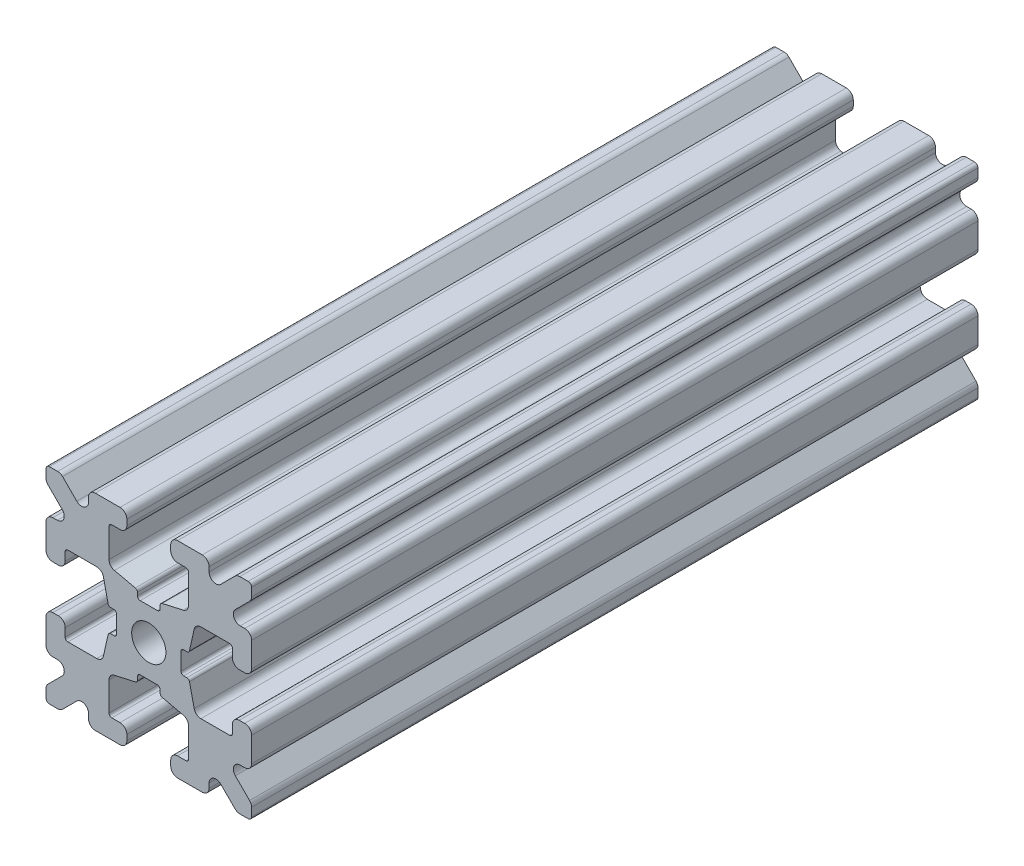
from build123d import *

# Parameters (mm, degrees)
SKETCH1_W           = 15
SKETCH1_H           = 15
SKETCH1_R           = 1.25
BOSS_EXTRUDE1_DEPTH = 26.5
FILLET1_R           = 0.25
CUT_EXTRUDE1_DEPTH  = 54
CUT_EXTRUDE3_DEPTH  = 54
FILLET3_R           = 0.5
FILLET4_R           = 0.5
FILLET5_R           = 3
FILLET6_R           = 0.2
CUT_EXTRUDE4_DEPTH  = 54
FILLET8_R           = 0.5
SKETCH6_W           = 5.1529354
SKETCH6_H           = 1.651
SKETCH6_W_2         = 1.651
SKETCH6_H_2         = 5.1529354
CUT_EXTRUDE5_DEPTH  = 54
FILLET10_R          = 0.2


with BuildPart() as part:
    # Sketch1 → Boss-Extrude1 (new body, symmetric)
    with BuildSketch(Plane.XY):
        Rectangle(SKETCH1_W, SKETCH1_H)
        Circle(SKETCH1_R, mode=Mode.SUBTRACT)
    extrude(amount=BOSS_EXTRUDE1_DEPTH, both=True)

    # Fillet1
    fillet1_edges = [part.edges().sort_by_distance(p)[0] for p in [
        (7.5, -7.5, 0),
        (-7.5, -7.5, 0),
        (-7.5, 7.5, 0),
        (7.5, 7.5, 0),
    ]]
    fillet(fillet1_edges, radius=FILLET1_R)

    # Sketch2 → Cut-Extrude1 (cut, through all)
    with BuildSketch(Plane.XY.offset(26.5)):
        Polygon((-7.5, 1.6), (-6.1, 1.6), (-6.1, 2.9), (-3.4, 2.9), (-3.4, -2.9), (-6.1, -2.9), (-6.1, -1.6), (-7.5, -1.6), align=None)
        Polygon((2.9, 6.1), (1.6, 6.1), (1.6, 7.5), (-1.6, 7.5), (-1.6, 6.1), (-2.9, 6.1), (-2.9, 3.4), (2.9, 3.4), align=None)
        Polygon((-1.6, -7.5), (-1.6, -6.1), (-2.9, -6.1), (-2.9, -3.4), (2.9, -3.4), (2.9, -6.1), (1.6, -6.1), (1.6, -7.5), align=None)
        Polygon((6.1, -2.9), (6.1, -1.6), (7.5, -1.6), (7.5, 1.6), (6.1, 1.6), (6.1, 2.9), (3.4, 2.9), (3.4, -2.9), align=None)
    extrude(amount=-CUT_EXTRUDE1_DEPTH, mode=Mode.SUBTRACT)

    # Sketch4 → Cut-Extrude3 (cut, through all)
    with BuildSketch(Plane.XY.offset(26.5)):
        Polygon((-3.4, 2.9), (-2.75, 0), (-3.4, -2.9), align=None)
        Polygon((-2.9, 3.4), (0, 2.75), (2.9, 3.4), align=None)
        Polygon((3.4, 2.9), (2.75, 0), (3.4, -2.9), align=None)
        Polygon((-2.9, -3.4), (0, -2.75), (2.9, -3.4), align=None)
    extrude(amount=-CUT_EXTRUDE3_DEPTH, mode=Mode.SUBTRACT)

    # Fillet3
    fillet3_edges = [part.edges().sort_by_distance(p)[0] for p in [
        (1.6, -7.5, 0),
        (-1.6, -7.5, 0),
        (-1.6, -6.1, 0),
        (1.6, -6.1, 0),
        (6.1, 1.6, 0),
        (7.5, 1.6, 0),
        (7.5, -1.6, 0),
        (6.1, -1.6, 0),
        (-7.5, -1.6, 0),
        (-7.5, 1.6, 0),
        (-6.1, 1.6, 0),
        (-6.1, -1.6, 0),
        (-1.6, 6.1, 0),
        (-1.6, 7.5, 0),
        (1.6, 7.5, 0),
        (1.6, 6.1, 0),
    ]]
    fillet(fillet3_edges, radius=FILLET3_R)

    # Fillet4
    fillet4_edges = [part.edges().sort_by_distance(p)[0] for p in [
        (-2.9, -3.4, 0),
        (2.9, -3.4, 0),
        (3.4, -2.9, 0),
        (3.4, 2.9, 0),
        (-3.4, 2.9, 0),
        (-3.4, -2.9, 0),
        (2.9, 3.4, 0),
        (-2.9, 3.4, 0),
    ]]
    fillet(fillet4_edges, radius=FILLET4_R)

    # Fillet5
    fillet5_edges = [part.edges().sort_by_distance(p)[0] for p in [
        (-2.75, 0, 0),
        (0, 2.75, 0),
        (2.75, 0, 0),
        (0, -2.75, 0),
    ]]
    fillet(fillet5_edges, radius=FILLET5_R)

    # Fillet6
    fillet6_edges = [part.edges().sort_by_distance(p)[0] for p in [
        (-2.9, -6.1, 0),
        (2.9, -6.1, 0),
        (6.1, -2.9, 0),
        (6.1, 2.9, 0),
        (-6.1, 2.9, 0),
        (-6.1, -2.9, 0),
        (2.9, 6.1, 0),
        (-2.9, 6.1, 0),
    ]]
    fillet(fillet6_edges, radius=FILLET6_R)

    # Sketch5 → Cut-Extrude4 (cut, through all)
    with BuildSketch(Plane.XY.offset(26.5)):
        Polygon((-7.5, 6.439339828), (-5.460660172, 4.4), (-7.5, 4.4), align=None)
        Polygon((-6.439339828, 7.5), (-4.4, 5.460660172), (-4.4, 7.5), align=None)
        Polygon((4.4, 7.5), (6.439339828, 7.5), (4.4, 5.460660172), align=None)
        Polygon((7.5, 6.439339828), (7.5, 4.4), (5.460660172, 4.4), align=None)
        Polygon((7.5, -6.439339828), (5.460660172, -4.4), (7.5, -4.4), align=None)
        Polygon((6.439339828, -7.5), (4.4, -5.460660172), (4.4, -7.5), align=None)
        Polygon((-4.4, -7.5), (-6.439339828, -7.5), (-4.4, -5.460660172), align=None)
        Polygon((-7.5, -6.439339828), (-7.5, -4.4), (-5.460660172, -4.4), align=None)
    extrude(amount=-CUT_EXTRUDE4_DEPTH, mode=Mode.SUBTRACT)

    # Fillet8
    fillet8_edges = [part.edges().sort_by_distance(p)[0] for p in [
        (-7.5, 4.4, 0),
        (-7.5, 6.439339828, 0),
        (-5.460660172, 4.4, 0),
        (7.5, -4.4, 0),
        (7.5, -6.439339828, 0),
        (5.460660172, -4.4, 0),
        (5.460660172, 4.4, 0),
        (7.5, 6.439339828, 0),
        (7.5, 4.4, 0),
        (-4.4, 7.5, 0),
        (-4.4, 5.460660172, 0),
        (-6.439339828, 7.5, 0),
        (-5.460660172, -4.4, 0),
        (-7.5, -6.439339828, 0),
        (-7.5, -4.4, 0),
        (4.4, 5.460660172, 0),
        (4.4, 7.5, 0),
        (6.439339828, 7.5, 0),
        (6.439339828, -7.5, 0),
        (4.4, -7.5, 0),
        (4.4, -5.460660172, 0),
        (-6.439339828, -7.5, 0),
        (-4.4, -5.460660172, 0),
        (-4.4, -7.5, 0),
    ]]
    fillet(fillet8_edges, radius=FILLET8_R)

    # Sketch6 → Cut-Extrude5 (cut, through all)
    with BuildSketch(Plane.XY.offset(26.5)):
        with Locations((4.9235323, 0)):
            Rectangle(SKETCH6_W, SKETCH6_H)
        with Locations((0, -4.9235323)):
            Rectangle(SKETCH6_W_2, SKETCH6_H_2)
        with Locations((-4.9235323, 0)):
            Rectangle(SKETCH6_W, SKETCH6_H)
        with Locations((0, 4.9235323)):
            Rectangle(SKETCH6_W_2, SKETCH6_H_2)
    extrude(amount=-CUT_EXTRUDE5_DEPTH, mode=Mode.SUBTRACT)

    # Fillet10
    fillet10_edges = [part.edges().sort_by_distance(p)[0] for p in [
        (0.8255, -2.935025862, 0),
        (-0.8255, -2.935025862, 0),
        (0.8255, -2.3470646, 0),
        (-0.8255, -2.3470646, 0),
        (2.935025862, 0.8255, 0),
        (2.935025862, -0.8255, 0),
        (2.3470646, 0.8255, 0),
        (2.3470646, -0.8255, 0),
        (-2.935025862, -0.8255, 0),
        (-2.935025862, 0.8255, 0),
        (-2.3470646, -0.8255, 0),
        (-2.3470646, 0.8255, 0),
        (-0.8255, 2.935025862, 0),
        (0.8255, 2.935025862, 0),
        (-0.8255, 2.3470646, 0),
        (0.8255, 2.3470646, 0),
    ]]
    fillet(fillet10_edges, radius=FILLET10_R)


solid = part.part
